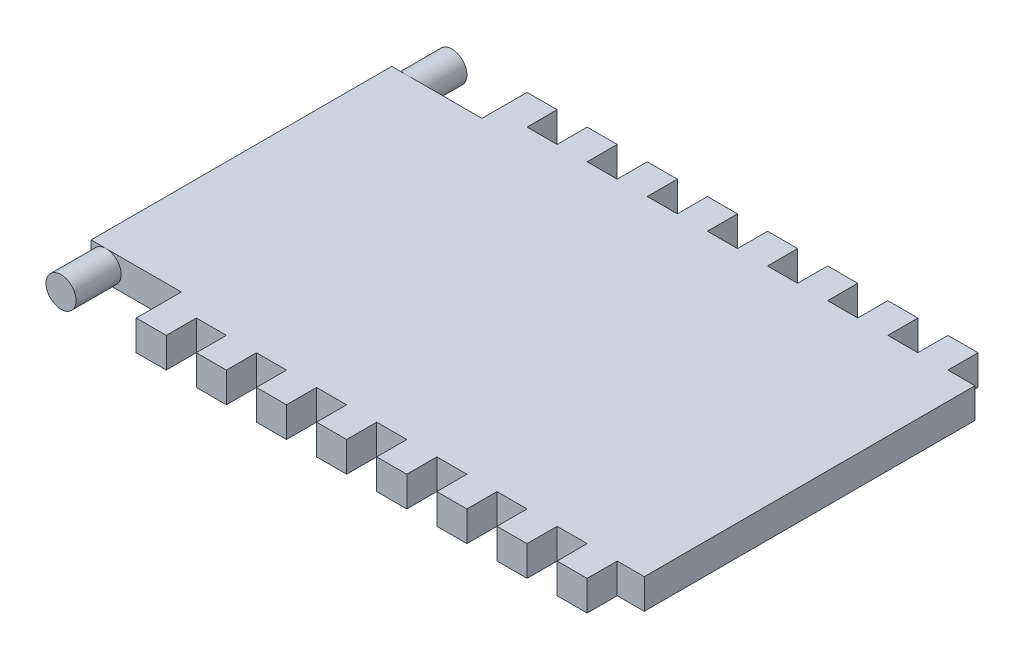
from build123d import *

# Parameters (mm, degrees)
ESQUISSE1_W                = 189
ESQUISSE1_H                = 130
BOSS_EXTRU_1_DEPTH         = 10
ESQUISSE2_W                = 30
ESQUISSE2_H                = 15
ENL_V_MAT_EXTRU_1_DEPTH    = 10
ESQUISSE3_W                = 10
ESQUISSE3_H                = 10
ENL_V_MAT_EXTRU_2_DEPTH    = 10
R_P_TITION_LIN_AIRE1_COUNT = 8
R_P_TITION_LIN_AIRE1_PITCH = 20
ESQUISSE4_R                = 5
BOSS_EXTRU_2_DEPTH         = 15
ESQUISSE5_R                = 5
BOSS_EXTRU_4_DEPTH         = 15


with BuildPart() as part:
    # Esquisse1 → Boss.-Extru.1 (new body)
    with BuildSketch(Plane(origin=(0, 0, 0), x_dir=(1, 0, 0), z_dir=(0, 1, 0))):
        with Locations((-94.5, 65)):
            Rectangle(ESQUISSE1_W, ESQUISSE1_H)
    extrude(amount=BOSS_EXTRU_1_DEPTH)

    # Esquisse2 → Enlèv. mat.-Extru.1 (cut)
    with BuildSketch(Plane(origin=(0, 10, 0), x_dir=(1, 0, 0), z_dir=(0, 1, 0))):
        with Locations((-174, 122.5)):
            Rectangle(ESQUISSE2_W, ESQUISSE2_H)
        with Locations((-174, 7.5)):
            Rectangle(ESQUISSE2_W, ESQUISSE2_H)
    extrude(amount=-ENL_V_MAT_EXTRU_1_DEPTH, mode=Mode.SUBTRACT)

    # Esquisse3 → Enlèv. mat.-Extru.2 (cut)
    with BuildSketch(Plane(origin=(0, 10, 0), x_dir=(1, 0, 0), z_dir=(0, 1, 0))):
        with Locations((-144, 125)):
            Rectangle(ESQUISSE3_W, ESQUISSE3_H)
        with Locations((-144, 5)):
            Rectangle(ESQUISSE3_W, ESQUISSE3_H)
    enl_v_mat_extru_2 = extrude(amount=-ENL_V_MAT_EXTRU_2_DEPTH, mode=Mode.SUBTRACT)

    # Répétition linéaire1: Enlèv. mat.-Extru.2 ×8
    with Locations(*[(i * R_P_TITION_LIN_AIRE1_PITCH, 0, 0) for i in range(1, R_P_TITION_LIN_AIRE1_COUNT)]):
        add(enl_v_mat_extru_2, mode=Mode.SUBTRACT)

    # Esquisse4 → Boss.-Extru.2 (add)
    with BuildSketch(Plane.XY.offset(-15)):
        with Locations((-184, 5)):
            Circle(ESQUISSE4_R)
    extrude(amount=BOSS_EXTRU_2_DEPTH)

    # Esquisse5 → Boss.-Extru.4 (add)
    with BuildSketch(Plane(origin=(0, 0, -115), x_dir=(-1, 0, 0), z_dir=(0, 0, -1))):
        with Locations((184, 5)):
            Circle(ESQUISSE5_R)
    extrude(amount=BOSS_EXTRU_4_DEPTH)


solid = part.part
